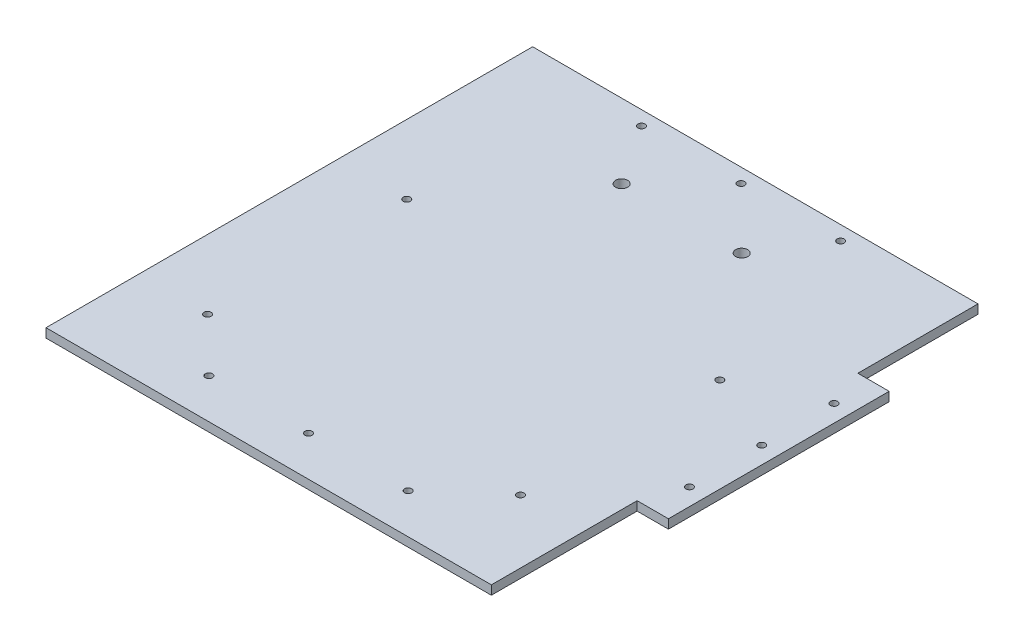
from build123d import *

# Parameters (mm, degrees)
SKETCH1_W           = 313
SKETCH1_H           = 342
BOSS_EXTRUDE1_DEPTH = 6.35
SKETCH3_W           = 22
SKETCH3_H           = 155.14040353
SKETCH3_R           = 2.5
BOSS_EXTRUDE2_DEPTH = 6.35
SKETCH2_R           = 2.5
CUT_EXTRUDE1_DEPTH  = 7.35
SKETCH4_R           = 4.25
SKETCH4_R_2         = 2.5
CUT_EXTRUDE2_DEPTH  = 7.35


with BuildPart() as part:
    # Sketch1 → Boss-Extrude1 (new body)
    with BuildSketch(Plane(origin=(0, 0, 0), x_dir=(1, 0, 0), z_dir=(0, 1, 0))):
        Rectangle(SKETCH1_W, SKETCH1_H)
    extrude(amount=-BOSS_EXTRUDE1_DEPTH)

    # Sketch3 → Boss-Extrude2 (add)
    with BuildSketch(Plane(origin=(0, 0, 0), x_dir=(1, 0, 0), z_dir=(0, 1, 0))):
        with Locations((167.5, 9)):
            Rectangle(SKETCH3_W, SKETCH3_H)
        with Locations((166.5, 9)):
            Circle(SKETCH3_R, mode=Mode.SUBTRACT)
        with Locations((166.5, -41.8)):
            Circle(SKETCH3_R, mode=Mode.SUBTRACT)
        with Locations((166.5, 59.8)):
            Circle(SKETCH3_R, mode=Mode.SUBTRACT)
    extrude(amount=-BOSS_EXTRUDE2_DEPTH)

    # Sketch2 → Cut-Extrude1 (cut, through all)
    with BuildSketch(Plane(origin=(0, 0, 0), x_dir=(1, 0, 0), z_dir=(0, 1, 0))):
        with Locations((0, -143)):
            Circle(SKETCH2_R)
        with Locations((-70, -143)):
            Circle(SKETCH2_R)
        with Locations((70, -143)):
            Circle(SKETCH2_R)
        with Locations((-70, 161)):
            Circle(SKETCH2_R)
        with Locations((0, 161)):
            Circle(SKETCH2_R)
        with Locations((70, 161)):
            Circle(SKETCH2_R)
    extrude(amount=-CUT_EXTRUDE1_DEPTH, mode=Mode.SUBTRACT)

    # Sketch4 → Cut-Extrude2 (cut, through all)
    with BuildSketch(Plane(origin=(0, 0, 0), x_dir=(1, 0, 0), z_dir=(0, 1, 0))):
        with Locations((42.574237453, 118.86741573)):
            Circle(SKETCH4_R)
        with Locations((-41.829962547, 118.86741573)):
            Circle(SKETCH4_R)
        with Locations((-107.911484214, -106.065530058)):
            Circle(SKETCH4_R_2)
        with Locations((-107.911484214, 33.934469942)):
            Circle(SKETCH4_R_2)
        with Locations((112.088515786, 33.934469942)):
            Circle(SKETCH4_R_2)
        with Locations((112.088515786, -106.065530058)):
            Circle(SKETCH4_R_2)
    extrude(amount=-CUT_EXTRUDE2_DEPTH, mode=Mode.SUBTRACT)


solid = part.part
